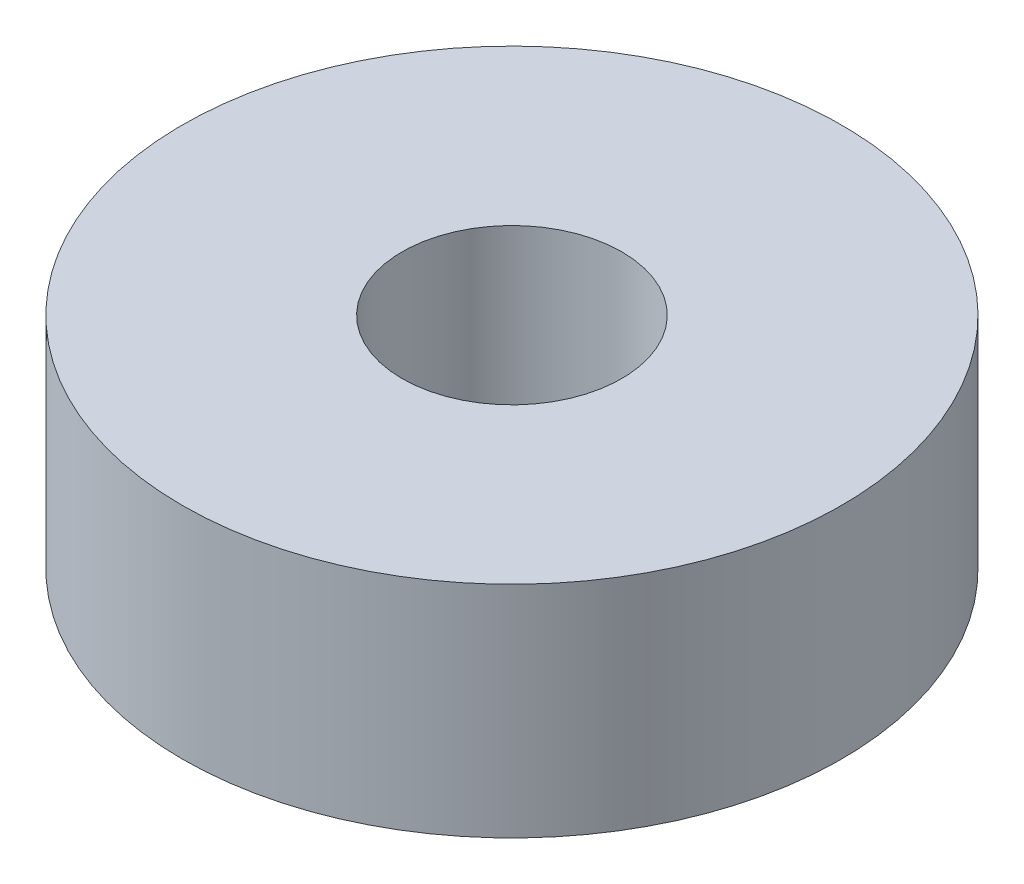
from build123d import *

# Parameters (mm, degrees)
SKETCH1_R           = 4.5
SKETCH1_R_2         = 1.5
BOSS_EXTRUDE1_DEPTH = 3


with BuildPart() as part:
    # Sketch1 → Boss-Extrude1 (new body)
    with BuildSketch(Plane(origin=(0, 0, 0), x_dir=(1, 0, 0), z_dir=(0, 1, 0))):
        Circle(SKETCH1_R)
        Circle(SKETCH1_R_2, mode=Mode.SUBTRACT)
    extrude(amount=BOSS_EXTRUDE1_DEPTH)


solid = part.part
